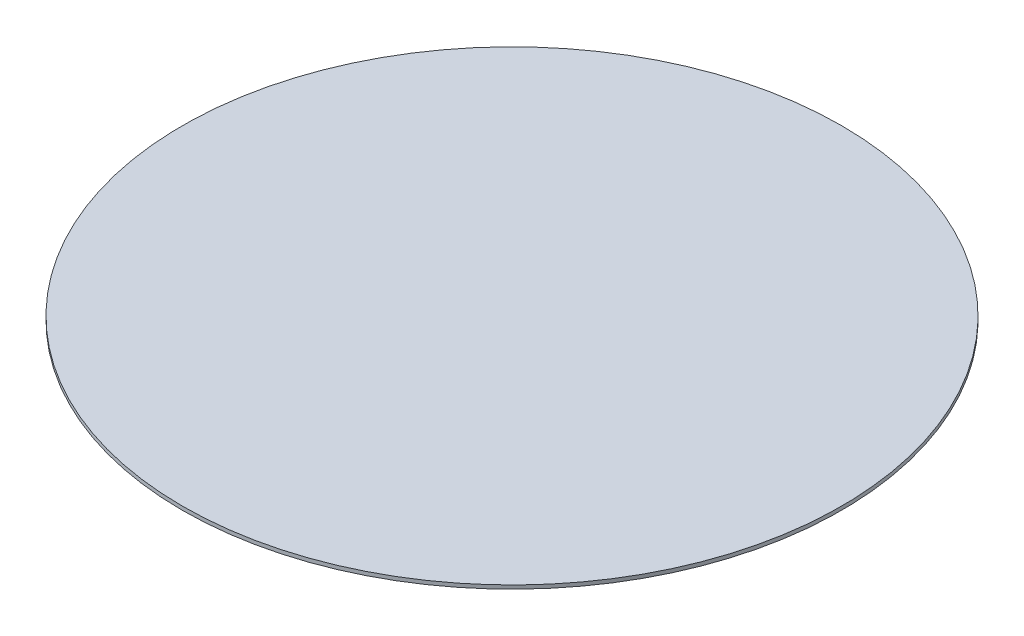
from build123d import *

# Parameters (mm, degrees)
SKETCH1_R           = 90
BOSS_EXTRUDE1_DEPTH = 1


with BuildPart() as part:
    # Sketch1 → Boss-Extrude1 (new body)
    with BuildSketch(Plane(origin=(0, 0, 0), x_dir=(1, 0, 0), z_dir=(0, 1, 0))):
        Circle(SKETCH1_R)
    extrude(amount=BOSS_EXTRUDE1_DEPTH)


solid = part.part
